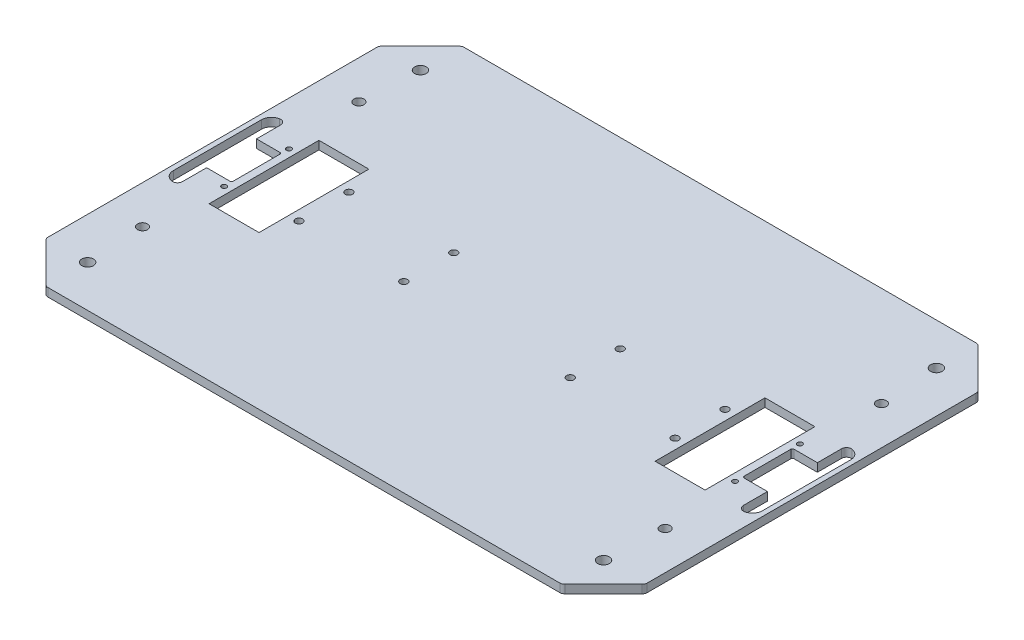
from build123d import *

# Parameters (mm, degrees)
BOSS_EXTRU_1_DEPTH         = 5
CONG_1_R                   = 3
ESQUISSE2_R                = 3
PER_AGE_PROFIL_DEPTH       = 6
ESQUISSE3_R                = 1.5
PER_AGE_ENCODEUR_DEPTH     = 6
POCHE_ROUE_ENCODEUSE_DEPTH = 6
CONG_2_R                   = 6
CONG_3_R                   = 3
ESQUISSE5_R                = 2.2
PER_AGE_BLOC_MOTEUR_DEPTH  = 6.0000001
ESQUISSE6_W                = 30
ESQUISSE6_H                = 66
POCHE_ROUE_MOTRICE_DEPTH   = 6.0000001
ESQUISSE7_R                = 3.5
PER_AGE_PATIN_DEPTH        = 6.0000001


with BuildPart() as part:
    # Esquisse1 → Boss.-Extru.1 (new body)
    with BuildSketch(Plane(origin=(0, 0, 0), x_dir=(1, 0, 0), z_dir=(0, 1, 0))):
        Polygon((-155, 125), (155, 125), (180, 100), (180, -100), (155, -125), (-155, -125), (-180, -100), (-180, 100), align=None)
    extrude(amount=BOSS_EXTRU_1_DEPTH)

    # Congé1
    cong_1_edges = [part.edges().sort_by_distance(p)[0] for p in [
        (180, 2.5, -100),
        (180, 2.5, 100),
        (155, 2.5, 125),
        (-155, 2.5, 125),
        (-180, 2.5, 100),
        (-180, 2.5, -100),
        (-155, 2.5, -125),
        (155, 2.5, -125),
    ]]
    fillet(cong_1_edges, radius=CONG_1_R)

    # Esquisse2 → Perçage Profilé (cut, through all)
    with BuildSketch(Plane(origin=(0, 5, 0), x_dir=(1, 0, 0), z_dir=(0, 1, 0))):
        with Locations((-157, -65)):
            Circle(ESQUISSE2_R)
        with Locations((-157, 65)):
            Circle(ESQUISSE2_R)
        with Locations((157, -65)):
            Circle(ESQUISSE2_R)
        with Locations((157, 65)):
            Circle(ESQUISSE2_R)
    extrude(amount=-PER_AGE_PROFIL_DEPTH, mode=Mode.SUBTRACT)

    # Esquisse3 → Perçage Encodeur (cut, through all)
    with BuildSketch(Plane(origin=(0, 5, 0), x_dir=(1, 0, 0), z_dir=(0, 1, 0))):
        with Locations((-153.5, 19.5)):
            Circle(ESQUISSE3_R)
        with Locations((-153.5, -19.5)):
            Circle(ESQUISSE3_R)
        with Locations((153.5, -19.5)):
            Circle(ESQUISSE3_R)
        with Locations((153.5, 19.5)):
            Circle(ESQUISSE3_R)
    extrude(amount=-PER_AGE_ENCODEUR_DEPTH, mode=Mode.SUBTRACT)

    # Esquisse4 → Poche Roue Encodeuse (cut, through all)
    with BuildSketch(Plane(origin=(0, 5, 0), x_dir=(1, 0, 0), z_dir=(0, 1, 0))):
        with BuildLine():
            Line((168.5, -15), (154.5, -15))
            ThreePointArc((154.5, -15), (153.792893219, -14.707106781), (153.5, -14))
            Line((153.5, -14), (153.5, 14))
            ThreePointArc((153.5, 14), (153.792893219, 14.707106781), (154.5, 15))
            Line((154.5, 15), (168.5, 15))
            Line((168.5, 15), (168.5, 32.5))
            Line((168.5, 32.5), (177, 32.5))
            Line((177, 32.5), (177, -32.5))
            Line((177, -32.5), (168.5, -32.5))
            Line((168.5, -32.5), (168.5, -15))
        make_face()
        with BuildLine():
            Line((-153.5, -14), (-153.5, 14))
            ThreePointArc((-153.5, 14), (-153.792893219, 14.707106781), (-154.5, 15))
            Line((-154.5, 15), (-168.5, 15))
            Line((-168.5, 15), (-168.5, 32.5))
            Line((-168.5, 32.5), (-177, 32.5))
            Line((-177, 32.5), (-177, -32.5))
            Line((-177, -32.5), (-168.5, -32.5))
            Line((-168.5, -32.5), (-168.5, -15))
            Line((-168.5, -15), (-154.5, -15))
            ThreePointArc((-154.5, -15), (-153.792893219, -14.707106781), (-153.5, -14))
        make_face()
    extrude(amount=-POCHE_ROUE_ENCODEUSE_DEPTH, mode=Mode.SUBTRACT)

    # Congé2
    cong_2_edges = [part.edges().sort_by_distance(p)[0] for p in [
        (-177, 2.5, 32.5),
        (-177, 2.5, -32.5),
        (177, 2.5, -32.5),
        (177, 2.5, 32.5),
    ]]
    fillet(cong_2_edges, radius=CONG_2_R)

    # Congé3
    cong_3_edges = [part.edges().sort_by_distance(p)[0] for p in [
        (168.5, 2.5, 32.5),
        (168.5, 2.5, -32.5),
        (-168.5, 2.5, 32.5),
        (-168.5, 2.5, -32.5),
    ]]
    fillet(cong_3_edges, radius=CONG_3_R)

    # Esquisse5 → Perçage Bloc Moteur (cut, through all)
    with BuildSketch(Plane(origin=(0, 5, 0), x_dir=(1, 0, 0), z_dir=(0, 1, 0))):
        with Locations((-113, 15)):
            Circle(ESQUISSE5_R)
        with Locations((-113, -15)):
            Circle(ESQUISSE5_R)
        with Locations((-50, -15)):
            Circle(ESQUISSE5_R)
        with Locations((-50, 15)):
            Circle(ESQUISSE5_R)
        with Locations((50, 15)):
            Circle(ESQUISSE5_R)
        with Locations((50, -15)):
            Circle(ESQUISSE5_R)
        with Locations((113, -15)):
            Circle(ESQUISSE5_R)
        with Locations((113, 15)):
            Circle(ESQUISSE5_R)
    extrude(amount=-PER_AGE_BLOC_MOTEUR_DEPTH, mode=Mode.SUBTRACT)

    # Esquisse6 → Poche Roue Motrice (cut, through all)
    with BuildSketch(Plane(origin=(0, 5, 0), x_dir=(1, 0, 0), z_dir=(0, 1, 0))):
        with Locations((-134, 0)):
            Rectangle(ESQUISSE6_W, ESQUISSE6_H)
        with Locations((134, 0)):
            Rectangle(ESQUISSE6_W, ESQUISSE6_H)
    extrude(amount=-POCHE_ROUE_MOTRICE_DEPTH, mode=Mode.SUBTRACT)

    # Esquisse7 → Perçage Patin (cut, through all)
    with BuildSketch(Plane(origin=(0, 5, 0), x_dir=(1, 0, 0), z_dir=(0, 1, 0))):
        with Locations((-155, 100)):
            Circle(ESQUISSE7_R)
        with Locations((-155, -100)):
            Circle(ESQUISSE7_R)
        with Locations((155, -100)):
            Circle(ESQUISSE7_R)
        with Locations((155, 100)):
            Circle(ESQUISSE7_R)
    extrude(amount=-PER_AGE_PATIN_DEPTH, mode=Mode.SUBTRACT)


solid = part.part
